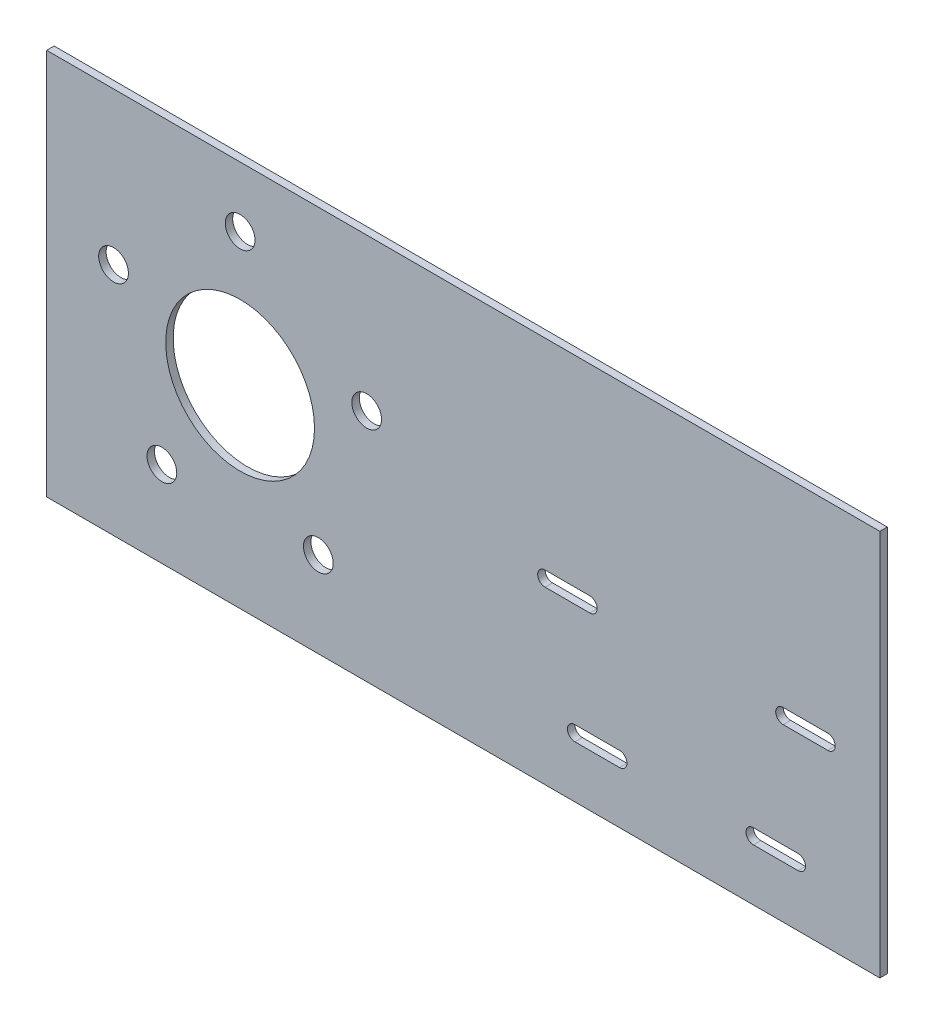
from build123d import *

# Parameters (mm, degrees)
SKETCH2_W           = 355.6
SKETCH2_H           = 165.1
SKETCH2_R           = 31.75
SKETCH2_R_2         = 6.35
BOSS_EXTRUDE1_DEPTH = 3.175
CUT_EXTRUDE1_DEPTH  = 4.175


with BuildPart() as part:
    # Sketch2 → Boss-Extrude1 (new body)
    with BuildSketch(Plane.XY):
        with Locations((95.25, 0)):
            Rectangle(SKETCH2_W, SKETCH2_H)
        Circle(SKETCH2_R, mode=Mode.SUBTRACT)
        with Locations((-54.018973032, 17.551828308)):
            Circle(SKETCH2_R_2, mode=Mode.SUBTRACT)
        with Locations((0, 56.798909535)):
            Circle(SKETCH2_R_2, mode=Mode.SUBTRACT)
        with Locations((54.018973032, 17.551828308)):
            Circle(SKETCH2_R_2, mode=Mode.SUBTRACT)
        with Locations((33.385561371, -45.951283076)):
            Circle(SKETCH2_R_2, mode=Mode.SUBTRACT)
        with Locations((-33.385561371, -45.951283076)):
            Circle(SKETCH2_R_2, mode=Mode.SUBTRACT)
    extrude(amount=BOSS_EXTRUDE1_DEPTH)

    # Sketch3 → Cut-Extrude1 (cut, through all)
    with BuildSketch(Plane.XY.offset(3.175)):
        with BuildLine():
            Line((149.225, -9.525), (130.175, -9.525))
            ThreePointArc((130.175, -9.525), (127, -6.35), (130.175, -3.175))
            Line((130.175, -3.175), (149.225, -3.175))
            ThreePointArc((149.225, -3.175), (152.4, -6.35), (149.225, -9.525))
        make_face()
        with BuildLine():
            Line((250.825, -9.525), (231.775, -9.525))
            ThreePointArc((231.775, -9.525), (228.6, -6.35), (231.775, -3.175))
            Line((231.775, -3.175), (250.825, -3.175))
            ThreePointArc((250.825, -3.175), (254, -6.35), (250.825, -9.525))
        make_face()
        with BuildLine():
            Line((238.125, -60.325), (219.075, -60.325))
            ThreePointArc((219.075, -60.325), (215.9, -57.15), (219.075, -53.975))
            Line((219.075, -53.975), (238.125, -53.975))
            ThreePointArc((238.125, -53.975), (241.3, -57.15), (238.125, -60.325))
        make_face()
        with BuildLine():
            Line((142.875, -53.975), (161.925, -53.975))
            ThreePointArc((161.925, -53.975), (165.1, -57.15), (161.925, -60.325))
            Line((161.925, -60.325), (142.875, -60.325))
            ThreePointArc((142.875, -60.325), (139.7, -57.15), (142.875, -53.975))
        make_face()
    extrude(amount=-CUT_EXTRUDE1_DEPTH, mode=Mode.SUBTRACT)


solid = part.part
